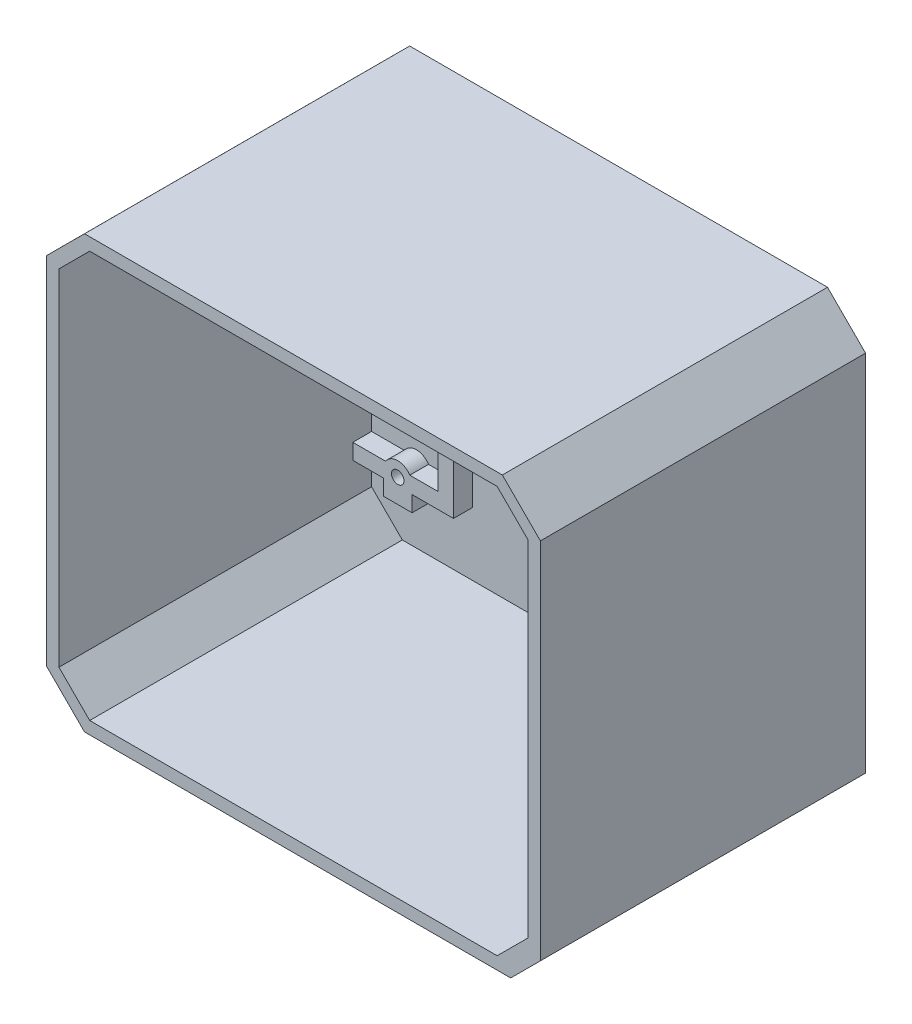
from build123d import *

# Parameters (mm, degrees)
BOSS_EXTRUDE3_DEPTH       = 2
SKETCH7_R                 = 1
SKETCH7_W                 = 2.5
SKETCH7_H                 = 2.5
BOSS_EXTRUDE5_DEPTH       = 3
SKETCH15_R                = 6.016109345
SKETCH15_R_2              = 2.966709341
CUT_EXTRUDE5_DEPTH        = 3
CUT_EXTRUDE6_DEPTH        = 3
CUT_EXTRUDE7_DEPTH        = 10
SKETCH31_W                = 2
SKETCH31_H                = 65
BOSS_EXTRUDE8_DEPTH       = 5
SKETCH36_R                = 6.012405266
CUT_EXTRUDE11_DEPTH       = 5
SKETCH37_R                = 2.966709341
CUT_EXTRUDE12_DEPTH       = 5
SKETCH38_W                = 3.192326617
SKETCH38_H                = 5.082846429
CUT_EXTRUDE13_DEPTH       = 5
BOSS_EXTRUDE13_DEPTH      = 50
BOSS_EXTRUDE13_DEPTH_BACK = 2


with BuildPart() as part:
    # Sketch2 → Boss-Extrude3 (new body)
    with BuildSketch(Plane.XY):
        Polygon((62.078732257, 67), (7.070378023, 67), (2.153513577, 62.087886246), (2.153513577, 6.916864445), (7.070378023, 2), (62.078732257, 2), (67.153513577, 7.083274694), (67.153513577, 61.921636784), align=None)
        with BuildLine():
            ThreePointArc((12.561398281, 29.386897281), (12.405099811, 29.087669445), (12.28230409, 28.773205265))
            ThreePointArc((12.28230409, 28.773205265), (9.332354964, 25.48092154), (6.384978263, 28.775508397))
            ThreePointArc((6.384978263, 28.775508397), (6.272687262, 29.080787813), (6.128559615, 29.372390302))
            ThreePointArc((6.128559615, 29.372390302), (9.319946418, 40.479834047), (12.561398281, 29.386897281))
        make_face(mode=Mode.SUBTRACT)
        with BuildLine():
            Line((7.315683042, 44.45), (3.053513577, 44.45))
            Line((3.053513577, 44.45), (3.053513577, 49.55))
            Line((3.053513577, 49.55), (15.603513577, 49.55))
            Line((15.603513577, 49.55), (15.603513577, 44.45))
            Line((15.603513577, 44.45), (11.175073004, 44.45))
            ThreePointArc((11.175073004, 44.45), (9.245378023, 45.49849), (7.315683042, 44.45))
        make_face(mode=Mode.SUBTRACT)
    boss_extrude3 = extrude(amount=BOSS_EXTRUDE3_DEPTH)

    # Sketch7 → Boss-Extrude5 (add)
    with BuildSketch(Plane.XY.offset(2)):
        with BuildLine():
            Line((15.753513577, 14.57), (11.264187035, 14.57))
            ThreePointArc((11.264187035, 14.57), (9.333513577, 15.62), (7.40284012, 14.57))
            Line((7.40284012, 14.57), (2.153513577, 14.57))
            Line((2.153513577, 14.57), (2.153513577, 12.07))
            Line((2.153513577, 12.07), (7.033513577, 12.07))
            Line((7.033513577, 12.07), (7.40284012, 12.07))
            ThreePointArc((7.40284012, 12.07), (9.333513577, 11.02), (11.264187035, 12.07))
            Line((11.264187035, 12.07), (11.633513577, 12.07))
            Line((11.633513577, 12.07), (15.753513577, 12.07))
            Line((15.753513577, 12.07), (15.753513577, 14.57))
        make_face()
        with Locations((9.333513577, 13.32)):
            Circle(SKETCH7_R, mode=Mode.SUBTRACT)
        with BuildLine():
            Line((11.633513577, 9.547776159), (11.633513577, 12.07))
            Line((11.633513577, 12.07), (11.264187035, 12.07))
            ThreePointArc((11.264187035, 12.07), (9.333513577, 11.02), (7.40284012, 12.07))
            Line((7.40284012, 12.07), (7.033513577, 12.07))
            Line((7.033513577, 12.07), (7.033513577, 9.547776159))
            Line((7.033513577, 9.547776159), (11.633513577, 9.547776159))
        make_face()
        with Locations((17.003513577, 13.32)):
            Rectangle(SKETCH7_W, SKETCH7_H)
        with BuildLine():
            Line((15.753513577, 16.534568208), (15.753513577, 14.57))
            Line((15.753513577, 14.57), (18.253513577, 14.57))
            Line((18.253513577, 14.57), (18.253513577, 16.534568208))
            Line((18.253513577, 16.534568208), (18.253513577, 44.45))
            Line((18.253513577, 44.45), (15.753513577, 44.45))
            Line((15.753513577, 44.45), (15.753513577, 44.44849))
            Line((15.753513577, 44.44849), (11.17605148, 44.44849))
            ThreePointArc((11.17605148, 44.44849), (11.17556239, 44.449245096), (11.175073004, 44.45))
            ThreePointArc((11.175073004, 44.45), (10.343450652, 45.219439406), (9.245378023, 45.49849))
            ThreePointArc((9.245378023, 45.49849), (8.147305393, 45.219439406), (7.315683042, 44.45))
            ThreePointArc((7.315683042, 44.45), (7.315193656, 44.449245096), (7.314704565, 44.44849))
            Line((7.314704565, 44.44849), (2.153513577, 44.44849))
            Line((2.153513577, 44.44849), (2.153513577, 41.94849))
            Line((2.153513577, 41.94849), (7.314704565, 41.94849))
            ThreePointArc((7.314704565, 41.94849), (9.245378023, 40.89849), (11.17605148, 41.94849))
            Line((11.17605148, 41.94849), (15.753513577, 41.94849))
            Line((15.753513577, 41.94849), (15.753513577, 16.534568208))
        make_face()
        with Locations((9.245378023, 43.19849)):
            Circle(SKETCH7_R, mode=Mode.SUBTRACT)
    boss_extrude5 = extrude(amount=BOSS_EXTRUDE5_DEPTH)

    # Mirror4: Boss-Extrude3, Boss-Extrude5 across plane
    add(boss_extrude3.mirror(Plane.ZY.offset(-34.653513577)))
    add(boss_extrude5.mirror(Plane.ZY.offset(-34.653513577)))

    # Sketch15 → Cut-Extrude5 (cut)
    with BuildSketch(Plane.XY.offset(2)):
        with Locations((9.333513577, 34.46374)):
            Circle(SKETCH15_R)
        with Locations((9.333513577, 28.447630655)):
            Circle(SKETCH15_R_2)
    cut_extrude5 = extrude(amount=-CUT_EXTRUDE5_DEPTH, mode=Mode.SUBTRACT)

    # Sketch21 → Cut-Extrude6 (cut)
    with BuildSketch(Plane.XY.offset(2)):
        with BuildLine():
            Line((3.317404233, 44.701735967), (7.504616246, 44.701735967))
            ThreePointArc((7.504616246, 44.701735967), (9.245378023, 45.49849), (10.986139799, 44.701735967))
            Line((10.986139799, 44.701735967), (15.349622922, 44.701735967))
            Line((15.349622922, 44.701735967), (15.349622922, 49.701735967))
            Line((15.349622922, 49.701735967), (3.317404233, 49.701735967))
            Line((3.317404233, 49.701735967), (3.317404233, 44.701735967))
        make_face()
    extrude(amount=-CUT_EXTRUDE6_DEPTH, mode=Mode.SUBTRACT)

    # Mirror5: Cut-Extrude5 across plane
    add(cut_extrude5.mirror(Plane.ZY.offset(-34.653513577)), mode=Mode.SUBTRACT)

    # Sketch29 → Cut-Extrude7 (cut)
    with BuildSketch(Plane.XY.offset(2)):
        with BuildLine():
            Line((3.317404233, 44.795528635), (7.590244313, 44.795528635))
            ThreePointArc((7.590244313, 44.795528635), (9.245378023, 45.49849), (10.900511733, 44.795528635))
            Line((10.900511733, 44.795528635), (15.349622922, 44.795528635))
            Line((15.349622922, 44.795528635), (15.349622922, 49.795528635))
            Line((15.349622922, 49.795528635), (3.317404233, 49.795528635))
            Line((3.317404233, 49.795528635), (3.317404233, 44.795528635))
        make_face()
    cut_extrude7 = extrude(amount=-CUT_EXTRUDE7_DEPTH, mode=Mode.SUBTRACT)

    # Mirror9: Cut-Extrude7 across plane
    add(cut_extrude7.mirror(Plane.ZY.offset(-34.653513577)), mode=Mode.SUBTRACT)

    # SurfaceCut1
    split(bisect_by=Plane.ZY.offset(-34.653513577), keep=Keep.TOP)

    # Sketch31 → Boss-Extrude8 (add)
    with BuildSketch(Plane(origin=(34.653513577, 0, 0), x_dir=(0, 0, -1), z_dir=(1, 0, 0))):
        with Locations((-1, 34.5)):
            Rectangle(SKETCH31_W, SKETCH31_H)
    extrude(amount=BOSS_EXTRUDE8_DEPTH)

    # Mirror13: Boss-Extrude3, Boss-Extrude5 across plane
    add(boss_extrude3.mirror(Plane(origin=(39.653513577, 0, 0), x_dir=(0, 0, 1), z_dir=(1, 0, 0))))
    add(boss_extrude5.mirror(Plane(origin=(39.653513577, 0, 0), x_dir=(0, 0, 1), z_dir=(1, 0, 0))))

    # Sketch36 → Cut-Extrude11 (cut)
    with BuildSketch(Plane.XY.offset(2)):
        with Locations((9.333513577, 34.46374)):
            Circle(SKETCH36_R)
    extrude(amount=-CUT_EXTRUDE11_DEPTH, mode=Mode.SUBTRACT)

    # Sketch37 → Cut-Extrude12 (cut)
    with BuildSketch(Plane.XY.offset(2)):
        with Locations((9.333513577, 28.447630655)):
            Circle(SKETCH37_R)
    extrude(amount=-CUT_EXTRUDE12_DEPTH, mode=Mode.SUBTRACT)

    # Sketch38 → Cut-Extrude13 (cut)
    with BuildSketch(Plane.XY.offset(2)):
        with Locations((13.749676886, 47.254105421)):
            Rectangle(SKETCH38_W, SKETCH38_H)
    extrude(amount=-CUT_EXTRUDE13_DEPTH, mode=Mode.SUBTRACT)

    # Sketch40 → Boss-Extrude13 (add, two sides)
    with BuildSketch(Plane.XY.offset(2)) as boss_extrude13_sk:
        Polygon((79.153513577, 4.750459826), (79.153513577, 62.91687969), (73.064510051, 69), (6.242517104, 69), (0.153513577, 62.91687969), (0.153513577, 6.088437321), (6.241950898, 0), (74.403053751, 0), align=None)
        Polygon((7.070378023, 67), (72.236649132, 67), (77.153513577, 62.087886246), (77.153513577, 6.916864445), (72.236649132, 2), (7.070378023, 2), (2.153513577, 6.916864445), (2.153513577, 62.087886246), align=None, mode=Mode.SUBTRACT)
    extrude(amount=BOSS_EXTRUDE13_DEPTH)
    extrude(boss_extrude13_sk.sketch, amount=-BOSS_EXTRUDE13_DEPTH_BACK)


solid = part.part
